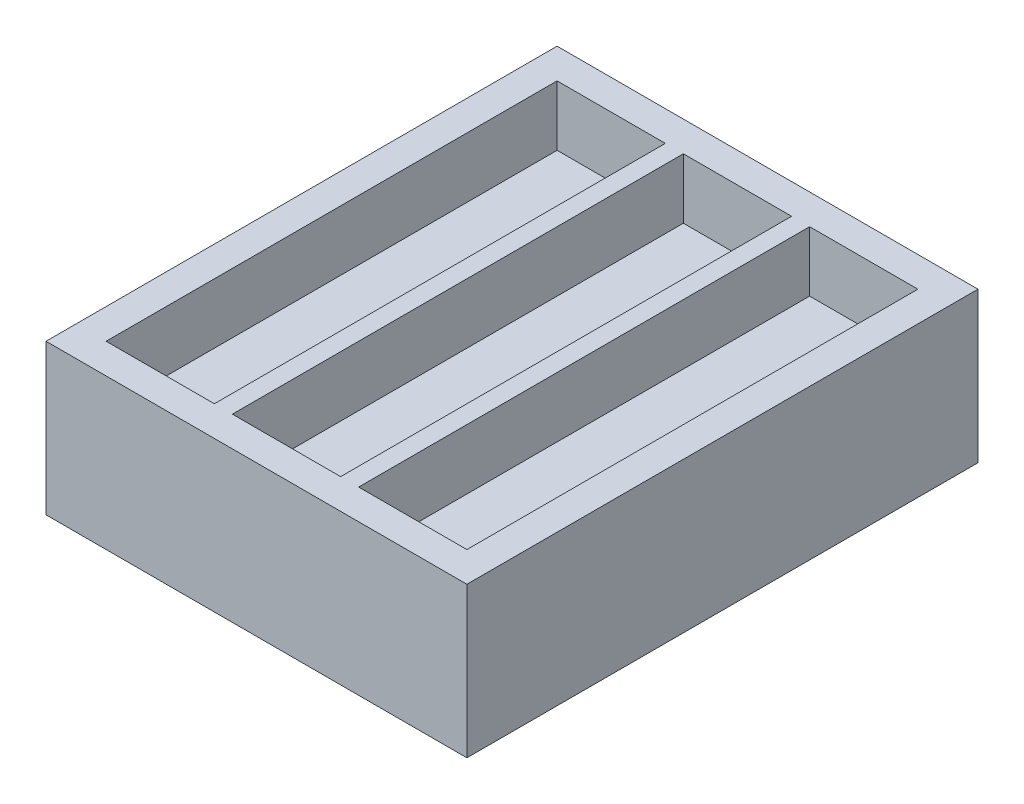
from build123d import *

# Parameters (mm, degrees)
SKETCH1_W           = 70
SKETCH1_H           = 85
BOSS_EXTRUDE1_DEPTH = 25
SKETCH2_W           = 18
SKETCH2_H           = 75
CUT_EXTRUDE1_DEPTH  = 10


with BuildPart() as part:
    # Sketch1 → Boss-Extrude1 (new body)
    with BuildSketch(Plane(origin=(0, 0, 0), x_dir=(1, 0, 0), z_dir=(0, 1, 0))):
        Rectangle(SKETCH1_W, SKETCH1_H)
    extrude(amount=BOSS_EXTRUDE1_DEPTH)

    # Sketch2 → Cut-Extrude1 (cut)
    with BuildSketch(Plane(origin=(0, 25, 0), x_dir=(1, 0, 0), z_dir=(0, 1, 0))):
        with Locations((-21, 0)):
            Rectangle(SKETCH2_W, SKETCH2_H)
        Rectangle(SKETCH2_W, SKETCH2_H)
        with Locations((21, 0)):
            Rectangle(SKETCH2_W, SKETCH2_H)
    extrude(amount=-CUT_EXTRUDE1_DEPTH, mode=Mode.SUBTRACT)


solid = part.part
